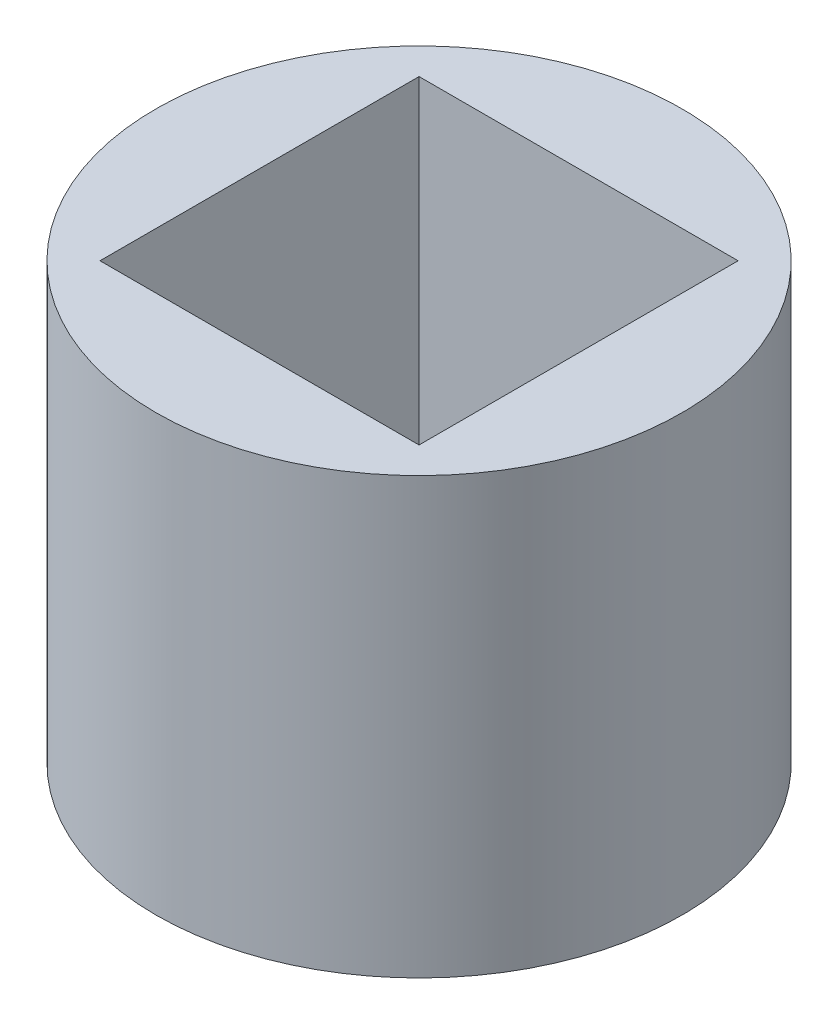
from build123d import *

# Parameters (mm, degrees)
SKETCH2_R           = 12.7
SKETCH2_W           = 15.4
SKETCH2_H           = 15.4
BOSS_EXTRUDE2_DEPTH = 21


with BuildPart() as part:
    # Sketch2 → Boss-Extrude2 (new body)
    with BuildSketch(Plane(origin=(0, 0, 0), x_dir=(1, 0, 0), z_dir=(0, 1, 0))):
        Circle(SKETCH2_R)
        Rectangle(SKETCH2_W, SKETCH2_H, mode=Mode.SUBTRACT)
    extrude(amount=BOSS_EXTRUDE2_DEPTH)


solid = part.part
